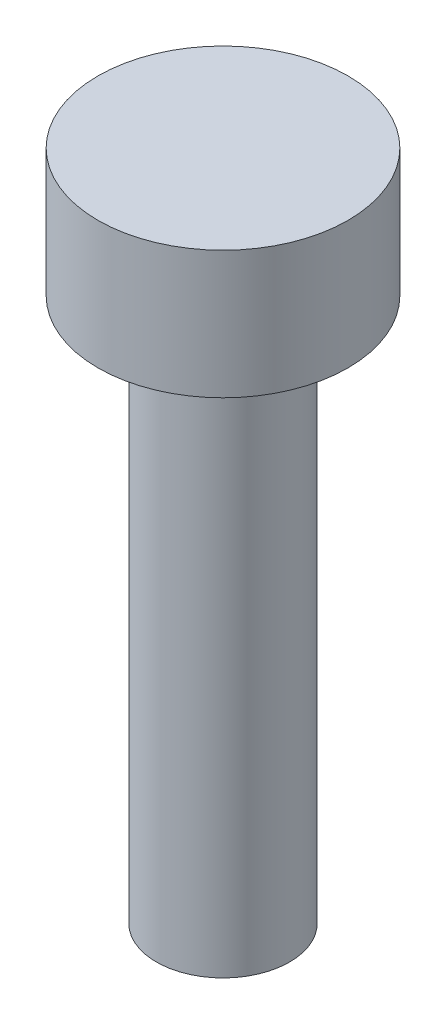
from build123d import *

# Parameters (mm, degrees)
SKETCH1_R           = 1.84
BOSS_EXTRUDE1_DEPTH = 1.88
SKETCH2_R           = 0.98
BOSS_EXTRUDE2_DEPTH = 8


with BuildPart() as part:
    # Sketch1 → Boss-Extrude1 (new body)
    with BuildSketch(Plane(origin=(0, 0, 0), x_dir=(1, 0, 0), z_dir=(0, 1, 0))):
        Circle(SKETCH1_R)
    extrude(amount=BOSS_EXTRUDE1_DEPTH)

    # Sketch2 → Boss-Extrude2 (add)
    with BuildSketch(Plane.XZ):
        Circle(SKETCH2_R)
    extrude(amount=BOSS_EXTRUDE2_DEPTH)


solid = part.part
